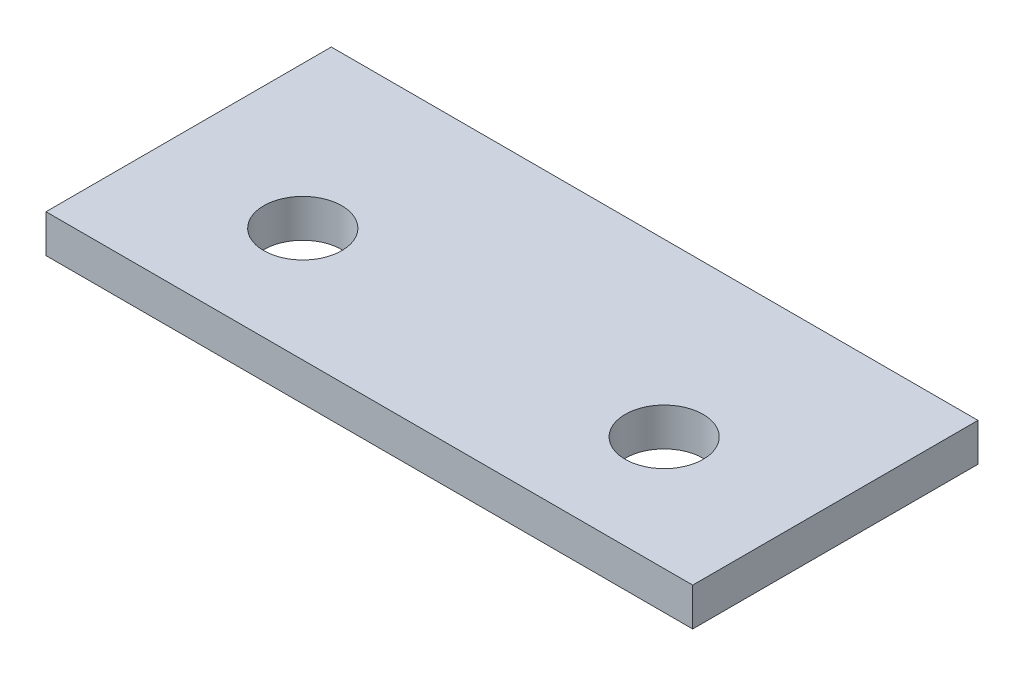
from build123d import *

# Parameters (mm, degrees)
SKETCH_1_W      = 68
SKETCH_1_H      = 30
SKETCH_1_R      = 4.1
EXTRUDE_1_DEPTH = 4


with BuildPart() as part:
    # Эскиз1 → Бобышка-Вытянуть1 (new body)
    with BuildSketch(Plane(origin=(0, 0, 0), x_dir=(1, 0, 0), z_dir=(0, 1, 0))):
        with Locations((34, 15)):
            Rectangle(SKETCH_1_W, SKETCH_1_H)
        with Locations((15, 12)):
            Circle(SKETCH_1_R, mode=Mode.SUBTRACT)
        with Locations((53, 12)):
            Circle(SKETCH_1_R, mode=Mode.SUBTRACT)
    extrude(amount=EXTRUDE_1_DEPTH)


solid = part.part
